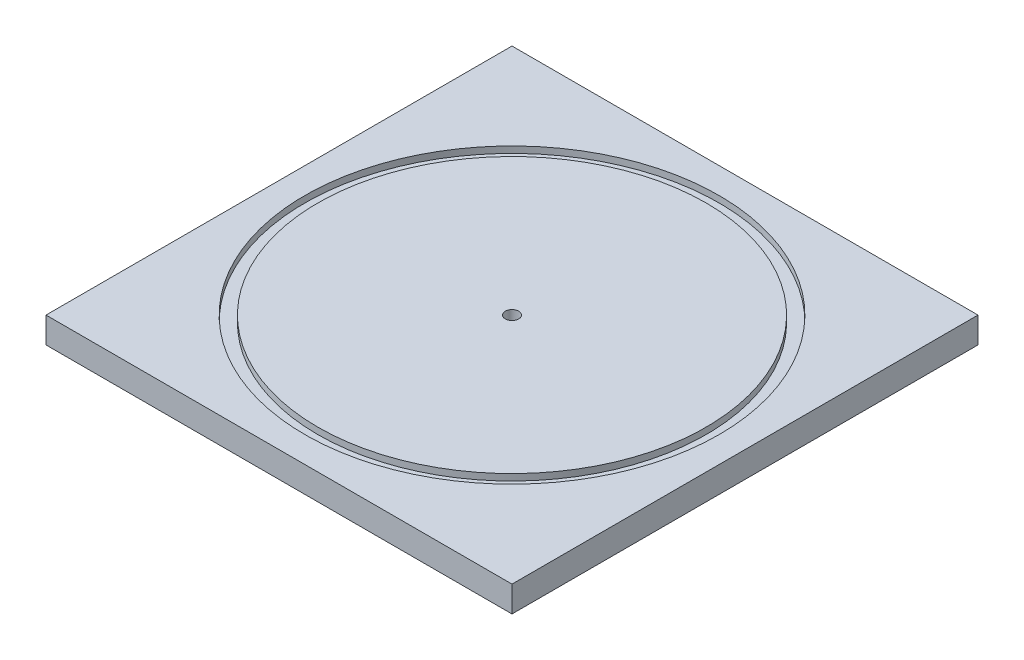
from build123d import *

# Parameters (mm, degrees)
SKETCH1_W               = 114.3
SKETCH1_H               = 114.3
BOSS_EXTRUDE1_DEPTH     = 6.35
SKETCH2_R               = 50.8
SKETCH2_R_2             = 47.625
CUT_EXTRUDE_THIN1_DEPTH = 1.5875
SKETCH3_R               = 1.651
CUT_EXTRUDE1_DEPTH      = 3.175


with BuildPart() as part:
    # Sketch1 → Boss-Extrude1 (new body)
    with BuildSketch(Plane(origin=(0, 0, 0), x_dir=(1, 0, 0), z_dir=(0, 1, 0))):
        Rectangle(SKETCH1_W, SKETCH1_H)
    extrude(amount=BOSS_EXTRUDE1_DEPTH)

    # Sketch2 → Cut-Extrude-Thin1 (cut)
    with BuildSketch(Plane(origin=(0, 6.35, 0), x_dir=(1, 0, 0), z_dir=(0, 1, 0))):
        Circle(SKETCH2_R)
        Circle(SKETCH2_R_2, mode=Mode.SUBTRACT)
    extrude(amount=-CUT_EXTRUDE_THIN1_DEPTH, mode=Mode.SUBTRACT)

    # Sketch3 → Cut-Extrude1 (cut)
    with BuildSketch(Plane(origin=(0, 6.35, 0), x_dir=(1, 0, 0), z_dir=(0, 1, 0))):
        Circle(SKETCH3_R)
    extrude(amount=-CUT_EXTRUDE1_DEPTH, mode=Mode.SUBTRACT)


solid = part.part
